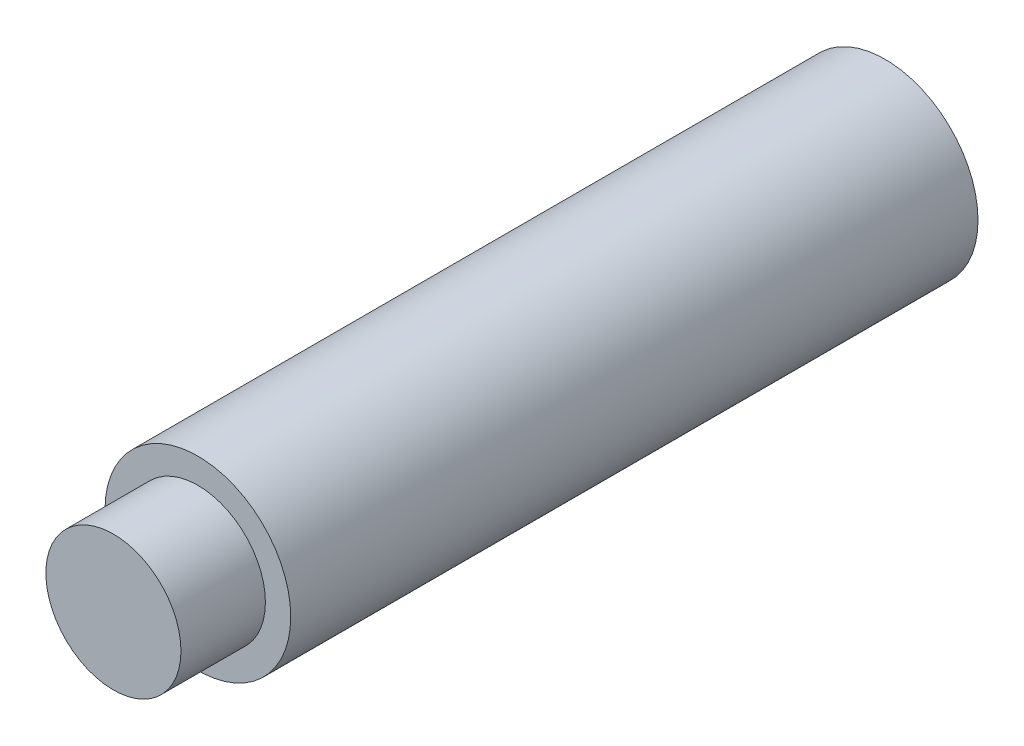
from build123d import *

# Parameters (mm, degrees)
SKETCH1_R                       = 5.5
BOSS_EXTRUDE1_DEPTH             = 40.7
SKETCH2_R                       = 4
BOSS_EXTRUDE2_DEPTH             = 5
M6X1_0_TAPPED_HOLE1_D           = 5
M6X1_0_TAPPED_HOLE1_DEPTH       = 7
M6X1_0_TAPPED_HOLE1_CSINK_D     = 6.05
M6X1_0_TAPPED_HOLE1_CSINK_ANGLE = 90
M6X1_0_TAPPED_HOLE1_TIP         = 1.502151548


with BuildPart() as part:
    # Sketch1 → Boss-Extrude1 (new body)
    with BuildSketch(Plane.XY):
        Circle(SKETCH1_R)
    extrude(amount=BOSS_EXTRUDE1_DEPTH)

    # Sketch2 → Boss-Extrude2 (add)
    with BuildSketch(Plane.XY.offset(40.7)):
        Circle(SKETCH2_R)
    extrude(amount=BOSS_EXTRUDE2_DEPTH)

    # M6x1.0 Tapped Hole1
    with Locations(Plane(origin=(0, 0, 0), x_dir=(-1, 0, 0), z_dir=(0, 0, -1))):
        with Locations((0, 0)):
            CounterSinkHole(M6X1_0_TAPPED_HOLE1_D / 2, M6X1_0_TAPPED_HOLE1_CSINK_D / 2, depth=M6X1_0_TAPPED_HOLE1_DEPTH, counter_sink_angle=M6X1_0_TAPPED_HOLE1_CSINK_ANGLE)
            with Locations((0, 0, -(M6X1_0_TAPPED_HOLE1_DEPTH + M6X1_0_TAPPED_HOLE1_TIP / 2))):  # 118° drill point
                Cone(0, M6X1_0_TAPPED_HOLE1_D / 2, M6X1_0_TAPPED_HOLE1_TIP, mode=Mode.SUBTRACT)


solid = part.part
